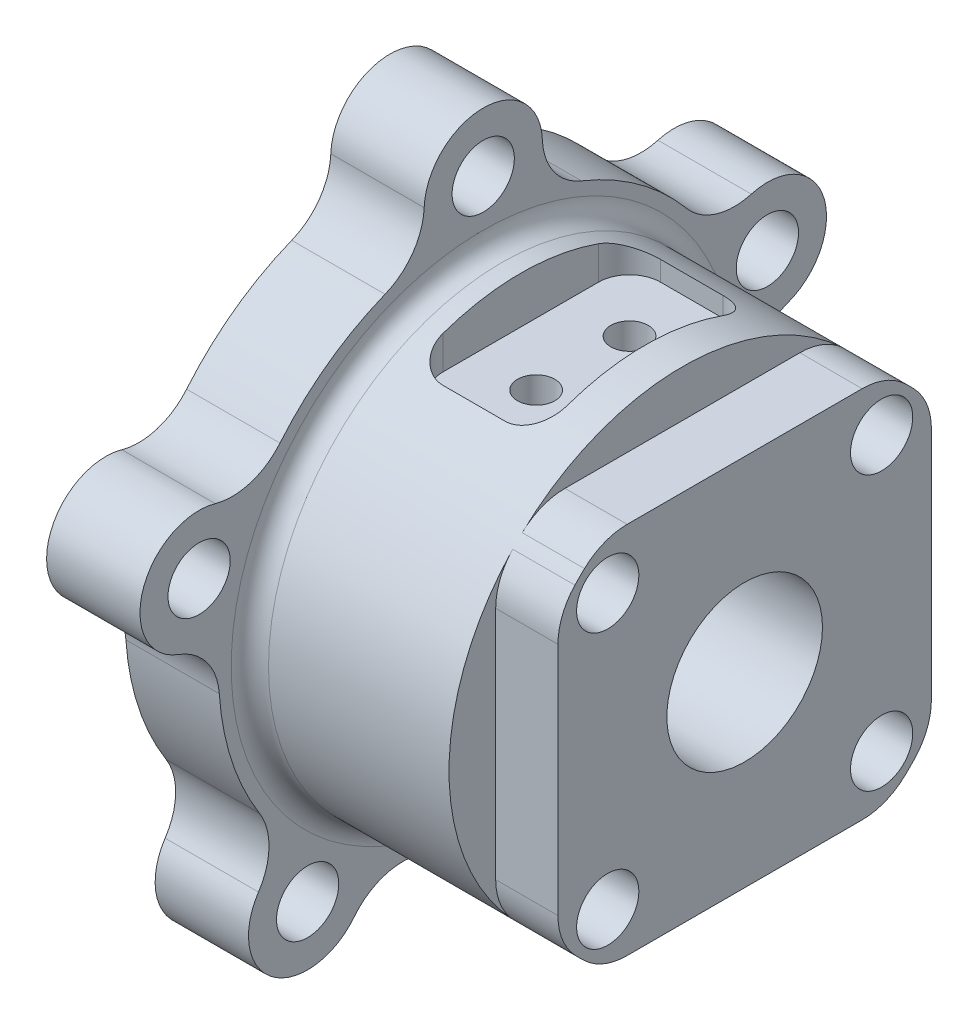
from build123d import *

# Parameters (mm, degrees)
SKETCH2_R                 = 48.134382163
SKETCH2_W                 = 60
SKETCH2_H                 = 60
CUT_EXTRUDE1_DEPTH        = 10
FILLET1_R                 = 10
F_10_0MM_DOWEL_HOLE2_D    = 10
CUT_EXTRUDE2_START        = 30
SKETCH5_W                 = 20
SKETCH5_H                 = 35
CUT_EXTRUDE2_DEPTH        = 28.5
FILLET2_R                 = 5
F_6_0MM_DOWEL_HOLE1_D     = 6
F_6_0MM_DOWEL_HOLE1_DEPTH = 25
F_6_0MM_DOWEL_HOLE1_TIP   = 1.802581857
F_10_0MM_DOWEL_HOLE1_D    = 10
CIRPATTERN1_COUNT         = 5
SKETCH11_R                = 67.5
CUT_EXTRUDE3_DEPTH        = 16
FILLET3_R                 = 10
F_25_0MM_DOWEL_HOLE1_D    = 25
FILLET4_R                 = 3


with BuildPart() as part:
    # Sketch1 → Revolve1 (revolve)
    with BuildSketch(Plane.XY, mode=Mode.PRIVATE) as revolve1_sk:
        Polygon((0, 0), (0, 37.5), (-42, 37.5), (-42, 57.5), (-57, 57.5), (-57, 0), align=None)
    revolve(revolve1_sk.sketch.rotate(Axis((0, 0, 0), (-1, 0, 0)), 90), axis=Axis((0, 0, 0), (-1, 0, 0)))  # turned: the seam where the file's is

    # Sketch2 → Cut-Extrude1 (cut)
    with BuildSketch(Plane(origin=(0, 0, 0), x_dir=(0, 0, -1), z_dir=(1, 0, 0))):
        Circle(SKETCH2_R)
        Rectangle(SKETCH2_W, SKETCH2_H, mode=Mode.SUBTRACT)
    extrude(amount=-CUT_EXTRUDE1_DEPTH, mode=Mode.SUBTRACT)

    # Fillet1
    fillet1_edges = [part.edges().sort_by_distance(p)[0] for p in [
        (-5, -30, 22.5),
        (-5, -30, -22.5),
        (-5, -22.5, -30),
        (-5, 22.5, -30),
        (-5, 30, -22.5),
        (-5, 30, 22.5),
        (-5, 22.5, 30),
        (-5, -22.5, 30),
    ]]
    fillet(fillet1_edges, radius=FILLET1_R)

    # Ø10.0mm Dowel Hole2 (through all)
    with Locations(Plane(origin=(0, 0, 0), x_dir=(0, 0, -1), z_dir=(1, 0, 0))):
        with Locations((22, 22), (-22, 22), (-22, -22), (22, -22)):
            Hole(F_10_0MM_DOWEL_HOLE2_D / 2)

    # Sketch5 → Cut-Extrude2 (cut, through all)
    with BuildSketch(Plane(origin=(0, 0, 0), x_dir=(1, 0, 0), z_dir=(0, 1, 0)).offset(CUT_EXTRUDE2_START)):
        with Locations((-26, 0)):
            Rectangle(SKETCH5_W, SKETCH5_H)
    extrude(amount=CUT_EXTRUDE2_DEPTH, mode=Mode.SUBTRACT)

    # Fillet2
    fillet2_edges = [part.edges().sort_by_distance(p)[0] for p in [
        (-36, 31.583123952, -17.5),
        (-36, 31.583123952, 17.5),
        (-16, 31.583123952, 17.5),
        (-16, 31.583123952, -17.5),
    ]]
    fillet(fillet2_edges, radius=FILLET2_R)

    # Ø6.0mm Dowel Hole1
    with Locations(Plane(origin=(0, 30, 0), x_dir=(1, 0, 0), z_dir=(0, 1, 0))):
        with Locations((-26, 7.5), (-26, -7.5)):
            Hole(F_6_0MM_DOWEL_HOLE1_D / 2, depth=F_6_0MM_DOWEL_HOLE1_DEPTH)
            with Locations((0, 0, -(F_6_0MM_DOWEL_HOLE1_DEPTH + F_6_0MM_DOWEL_HOLE1_TIP / 2))):  # 118° drill point
                Cone(0, F_6_0MM_DOWEL_HOLE1_D / 2, F_6_0MM_DOWEL_HOLE1_TIP, mode=Mode.SUBTRACT)

    # Ø10.0mm Dowel Hole1 (through all)
    with Locations(Plane(origin=(-42, 0, 0), x_dir=(0, 0, -1), z_dir=(1, 0, 0))):
        with Locations((0, 48)):
            f_10_0mm_dowel_hole1 = Hole(F_10_0MM_DOWEL_HOLE1_D / 2)

    # CirPattern1: Ø10.0mm Dowel Hole1 ×5 about axis
    cirpattern1_axis = Axis((0, 0, 0), (1, 0, 0))
    for i in range(1, CIRPATTERN1_COUNT):
        add(f_10_0mm_dowel_hole1.rotate(cirpattern1_axis, i * 360 / CIRPATTERN1_COUNT), mode=Mode.SUBTRACT)

    # Sketch11 → Cut-Extrude3 (cut, through all)
    with BuildSketch(Plane(origin=(-42, 0, 0), x_dir=(0, 0, -1), z_dir=(1, 0, 0))):
        Circle(SKETCH11_R)
        with BuildLine():
            ThreePointArc((7.261843774, 41.875), (0, 57.5), (-7.261843774, 41.875))
            ThreePointArc((-7.261843774, 41.875), (-24.980873222, 34.383222261), (-37.581458483, 19.846510481))
            ThreePointArc((-37.581458483, 19.846510481), (-54.685749687, 17.768477177), (-42.069524757, 6.033662798))
            ThreePointArc((-42.069524757, 6.033662798), (-40.419901943, -13.133222261), (-30.488462464, -29.609181965))
            ThreePointArc((-30.488462464, -29.609181965), (-33.797652007, -46.518477177), (-18.738552416, -38.145991314))
            ThreePointArc((-18.738552416, -38.145991314), (0, -42.5), (18.738552416, -38.145991314))
            ThreePointArc((18.738552416, -38.145991314), (33.797652007, -46.518477177), (30.488462464, -29.609181965))
            ThreePointArc((30.488462464, -29.609181965), (40.419901943, -13.133222261), (42.069524757, 6.033662798))
            ThreePointArc((42.069524757, 6.033662798), (54.685749687, 17.768477177), (37.581458483, 19.846510481))
            ThreePointArc((37.581458483, 19.846510481), (24.980873222, 34.383222261), (7.261843774, 41.875))
        make_face(mode=Mode.SUBTRACT)
    extrude(amount=-CUT_EXTRUDE3_DEPTH, mode=Mode.SUBTRACT)

    # Fillet3
    fillet3_edges = [part.edges().sort_by_distance(p)[0] for p in [
        (-49.5, 19.846510481, 37.581458483),
        (-49.5, 41.875, -7.261843774),
        (-49.5, 6.033662798, -42.069524757),
        (-49.5, -38.145991314, -18.738552416),
        (-49.5, -29.609181965, 30.488462464),
        (-49.5, 6.033662798, 42.069524757),
        (-49.5, 41.875, 7.261843774),
        (-49.5, 19.846510481, -37.581458483),
        (-49.5, -29.609181965, -30.488462464),
        (-49.5, -38.145991314, 18.738552416),
    ]]
    fillet(fillet3_edges, radius=FILLET3_R)

    # Ø25.0mm Dowel Hole1 (through all)
    with Locations(Plane(origin=(0, 0, 0), x_dir=(0, 0, -1), z_dir=(1, 0, 0))):
        with Locations((0, 0)):
            Hole(F_25_0MM_DOWEL_HOLE1_D / 2)

    # Fillet4
    fillet4_edges = [part.edges().sort_by_distance(p)[0] for p in [
        (-42, 0, 37.5),
    ]]
    fillet(fillet4_edges, radius=FILLET4_R)


solid = part.part
